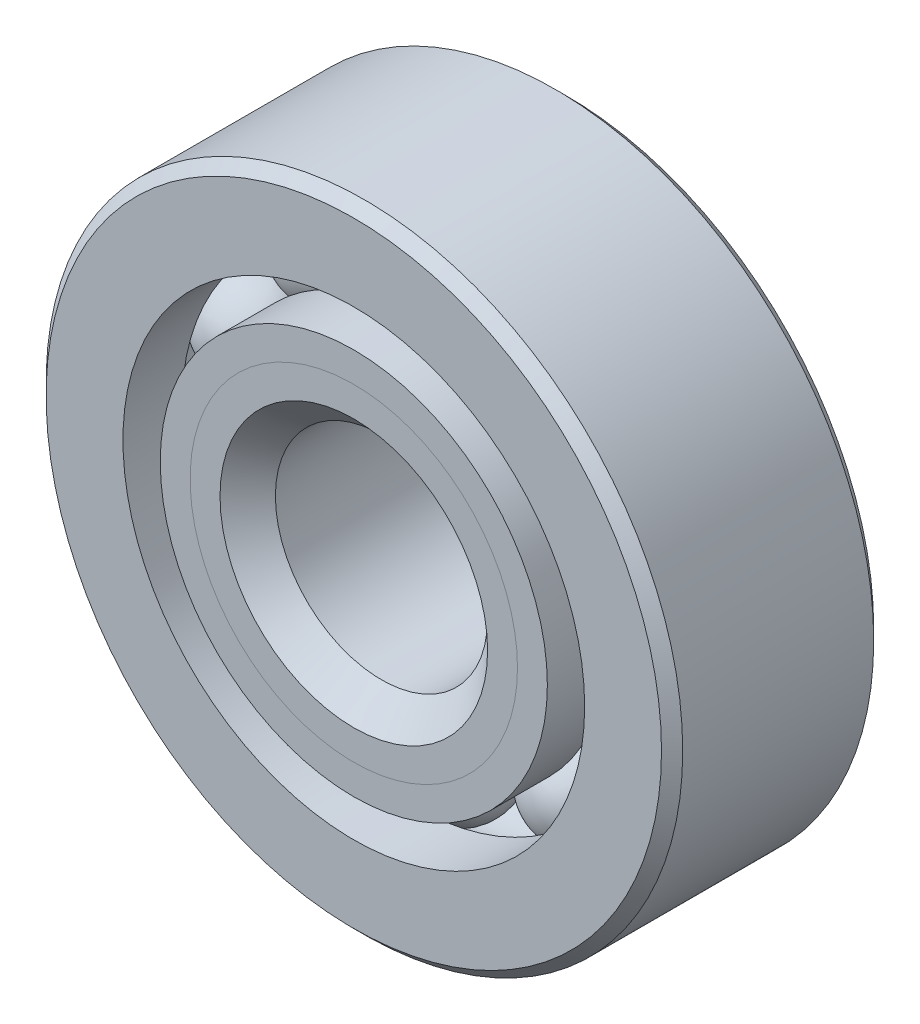
from build123d import *

# Parameters (mm, degrees)
CIRPATTERN1_COUNT = 10


with BuildPart() as part:
    # Sketch1 → Revolve1 (revolve)
    with BuildSketch(Plane(origin=(0, 0, 0), x_dir=(0, 0, -1), z_dir=(1, 0, 0))):
        with BuildLine():
            Line((4.28625, 14.2875), (-4.28625, 14.2875))
            Line((-4.28625, 14.2875), (-4.7625, 13.81125))
            Line((-4.7625, 13.81125), (-4.7625, 10.362362637))
            Line((-4.7625, 10.362362637), (-2.116666667, 10.362362637))
            ThreePointArc((-2.116666667, 10.362362637), (0, 11.801280731), (2.116666667, 10.362362637))
            Line((2.116666667, 10.362362637), (4.7625, 10.362362637))
            Line((4.7625, 10.362362637), (4.7625, 13.81125))
            Line((4.7625, 13.81125), (4.28625, 14.2875))
        make_face()
    revolve(axis=Axis((0, 0, 4.7625), (0, 0, -1)))


with BuildPart() as body_2:
    # Sketch2 → Revolve2 (revolve)
    with BuildSketch(Plane(origin=(0, 0, 0), x_dir=(0, 0, -1), z_dir=(1, 0, 0))):
        with BuildLine():
            Line((-4.7625, 8.687637363), (-2.116666667, 8.687637363))
            ThreePointArc((-2.116666667, 8.687637363), (-1.279722925, 7.642511434), (0, 7.248719269))
            Line((0, 7.248719269), (0, 6.005609635))
            Line((0, 6.005609635), (-3.421486136, 6.005609635))
            Line((-3.421486136, 6.005609635), (-4.7625, 7.346623499))
            Line((-4.7625, 7.346623499), (-4.7625, 8.687637363))
        make_face()
    revolve(axis=Axis((0, 0, 4.7625), (0, 0, -1)))


with BuildPart() as body_3:
    # Sketch3 → Revolve3 (revolve)
    with BuildSketch(Plane(origin=(0, 0, 0), x_dir=(0, 0, -1), z_dir=(1, 0, 0))):
        with BuildLine():
            Line((-4.7625, 7.346623499), (-3.421486136, 6.005609635))
            Line((-3.421486136, 6.005609635), (0, 6.005609635))
            Line((0, 6.005609635), (0, 7.248719269))
            ThreePointArc((0, 7.248719269), (1.279722925, 7.642511434), (2.116666667, 8.687637363))
            Line((2.116666667, 8.687637363), (4.7625, 8.687637363))
            Line((4.7625, 8.687637363), (4.7625, 5.23875))
            Line((4.7625, 5.23875), (4.28625, 4.7625))
            Line((4.28625, 4.7625), (-3.519390365, 4.7625))
            Line((-3.519390365, 4.7625), (-4.7625, 6.005609635))
            Line((-4.7625, 6.005609635), (-4.7625, 7.346623499))
        make_face()
    revolve(axis=Axis((0, 0, 4.7625), (0, 0, -1)))


with BuildPart() as body_4:
    # Sketch4 → Revolve4 (revolve)
    with BuildSketch(Plane(origin=(0, 0, 0), x_dir=(0, 0, -1), z_dir=(1, 0, 0))):
        with BuildLine():
            Line((-2.276280731, 9.525), (2.276280731, 9.525))
            ThreePointArc((2.276280731, 9.525), (0, 11.801280731), (-2.276280731, 9.525))
        make_face()
    revolve(axis=Axis((0, 9.525, 2.276280731), (0, 0, -1)))


with BuildPart() as cirpattern1_1:
    # CirPattern1: pattern copy
    add(body_4.part.rotate(Axis((0, 0, 0), (0, 0, 1)), 1 * 360 / CIRPATTERN1_COUNT))


with BuildPart() as cirpattern1_2:
    # CirPattern1: pattern copy
    add(body_4.part.rotate(Axis((0, 0, 0), (0, 0, 1)), 2 * 360 / CIRPATTERN1_COUNT))


with BuildPart() as cirpattern1_3:
    # CirPattern1: pattern copy
    add(body_4.part.rotate(Axis((0, 0, 0), (0, 0, 1)), 3 * 360 / CIRPATTERN1_COUNT))


with BuildPart() as cirpattern1_4:
    # CirPattern1: pattern copy
    add(body_4.part.rotate(Axis((0, 0, 0), (0, 0, 1)), 4 * 360 / CIRPATTERN1_COUNT))


with BuildPart() as cirpattern1_5:
    # CirPattern1: pattern copy
    add(body_4.part.rotate(Axis((0, 0, 0), (0, 0, 1)), 5 * 360 / CIRPATTERN1_COUNT))


with BuildPart() as cirpattern1_6:
    # CirPattern1: pattern copy
    add(body_4.part.rotate(Axis((0, 0, 0), (0, 0, 1)), 6 * 360 / CIRPATTERN1_COUNT))


with BuildPart() as cirpattern1_7:
    # CirPattern1: pattern copy
    add(body_4.part.rotate(Axis((0, 0, 0), (0, 0, 1)), 7 * 360 / CIRPATTERN1_COUNT))


with BuildPart() as cirpattern1_8:
    # CirPattern1: pattern copy
    add(body_4.part.rotate(Axis((0, 0, 0), (0, 0, 1)), 8 * 360 / CIRPATTERN1_COUNT))


with BuildPart() as cirpattern1_9:
    # CirPattern1: pattern copy
    add(body_4.part.rotate(Axis((0, 0, 0), (0, 0, 1)), 9 * 360 / CIRPATTERN1_COUNT))


solid = Compound([part.part, body_2.part, body_3.part, body_4.part, cirpattern1_1.part, cirpattern1_2.part, cirpattern1_3.part, cirpattern1_4.part, cirpattern1_5.part, cirpattern1_6.part, cirpattern1_7.part, cirpattern1_8.part, cirpattern1_9.part])
